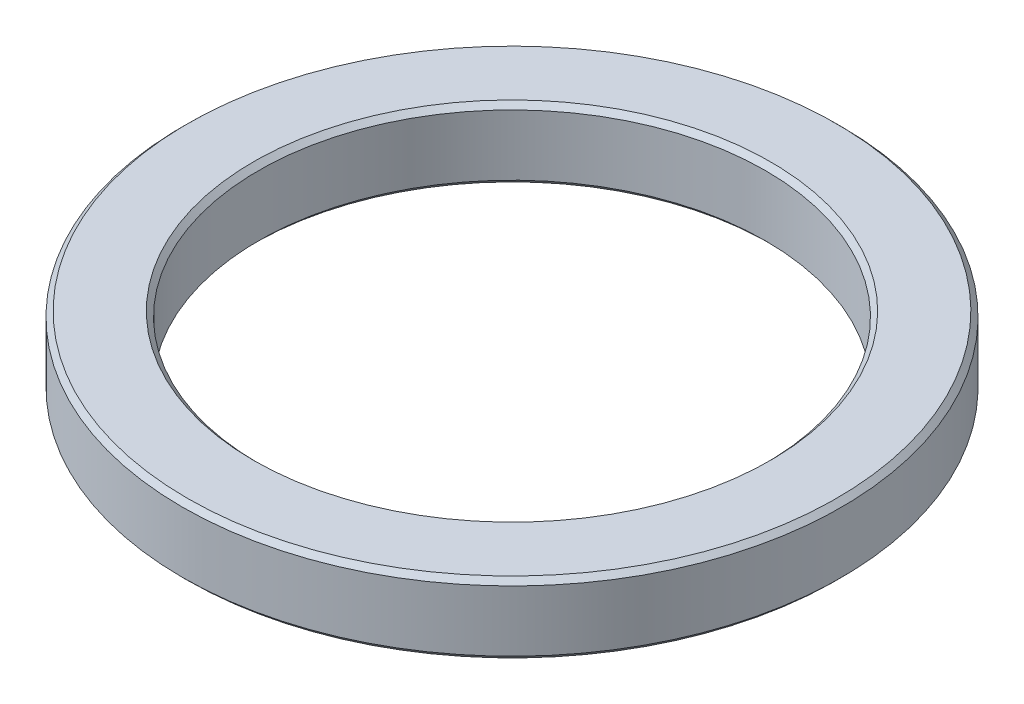
from build123d import *

# Parameters (mm, degrees)
SKETCH_1_R      = 32.5
SKETCH_1_R_2    = 25
EXTRUDE_1_DEPTH = 7
CHAMFER_1_SIZE  = 0.5


with BuildPart() as part:
    # 草图1 → 凸台-拉伸1 (new body)
    with BuildSketch(Plane(origin=(0, 0, 0), x_dir=(1, 0, 0), z_dir=(0, 1, 0))):
        Circle(SKETCH_1_R)
        Circle(SKETCH_1_R_2, mode=Mode.SUBTRACT)
    extrude(amount=EXTRUDE_1_DEPTH)

    # 倒角1
    chamfer_1_edges = [part.edges().sort_by_distance(p)[0] for p in [
        (-32.5, 0, 0),
        (-32.5, 7, 0),
        (-25, 0, 0),
        (-25, 7, 0),
    ]]
    chamfer(chamfer_1_edges, length=CHAMFER_1_SIZE)


solid = part.part
